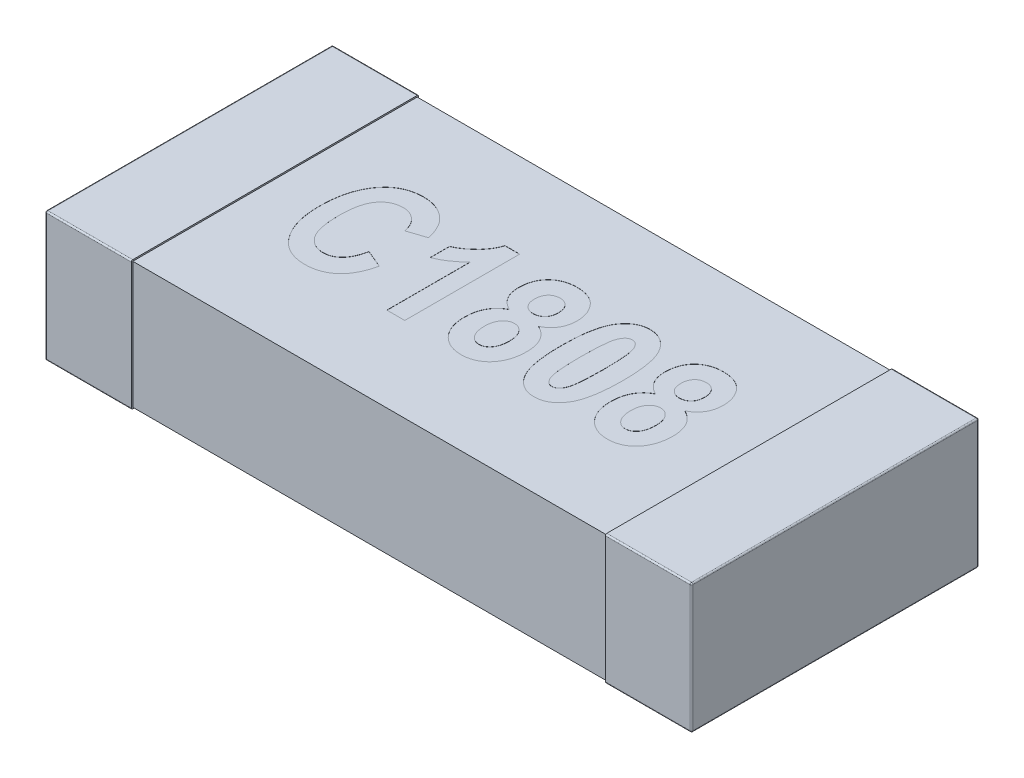
from build123d import *

# Parameters (mm, degrees)
SKETCH1_W            = 0.6
SKETCH1_H            = 2
THICKNESS_DEPTH      = 0.9
FILLET1_R            = 0.01
SKETCH2_W            = 1.98
SKETCH2_H            = 0.88
BOSS_EXTRUDE2_DEPTH  = 1.65
FILLET1_OF_MIRROR3_R = 0.01
CUT_EXTRUDE1_DEPTH   = 0.001


with BuildPart() as part:
    # Sketch1 → THICKNESS (new body)
    with BuildSketch(Plane(origin=(0, 0, 0), x_dir=(1, 0, 0), z_dir=(0, 1, 0))):
        with Locations((-1.95, 0)):
            Rectangle(SKETCH1_W, SKETCH1_H)
    thickness = extrude(amount=THICKNESS_DEPTH)

    # Fillet1
    fillet1_edges = [part.edges().sort_by_distance(p)[0] for p in [
        (-1.95, 0.9, -1),
        (-2.25, 0.9, 0),
        (-1.95, 0, -1),
        (-1.95, 0, 1),
        (-2.25, 0, 0),
        (-1.95, 0.9, 1),
        (-2.25, 0.45, -1),
        (-2.25, 0.45, 1),
    ]]
    fillet(fillet1_edges, radius=FILLET1_R)

    # Sketch2 → Boss-Extrude2 (add)
    with BuildSketch(Plane(origin=(0, 0, 0), x_dir=(0, 0, -1), z_dir=(1, 0, 0))):
        with Locations((0, 0.45)):
            Rectangle(SKETCH2_W, SKETCH2_H)
    boss_extrude2 = extrude(amount=-BOSS_EXTRUDE2_DEPTH)

    # Mirror3: THICKNESS, Boss-Extrude2 across plane
    add(thickness.mirror(Plane(origin=(0, 0, 0), x_dir=(0, 0, 1), z_dir=(1, 0, 0))))
    add(boss_extrude2.mirror(Plane(origin=(0, 0, 0), x_dir=(0, 0, 1), z_dir=(1, 0, 0))))

    # Fillet1 of Mirror3
    fillet1_of_mirror3_edges = [part.edges().sort_by_distance(p)[0] for p in [
        (1.95, 0.9, -1),
        (2.25, 0.9, 0),
        (1.95, 0, -1),
        (1.95, 0, 1),
        (2.25, 0, 0),
        (1.95, 0.9, 1),
        (2.25, 0.45, -1),
        (2.25, 0.45, 1),
    ]]
    fillet(fillet1_of_mirror3_edges, radius=FILLET1_OF_MIRROR3_R)

    # Sketch3 → Cut-Extrude1 (cut)
    with BuildSketch(Plane(origin=(0, 0.89, 0), x_dir=(1, 0, 0), z_dir=(0, 1, 0))):
        with BuildLine():
            Line((-0.886688312, -0.109090909), (-0.762012987, -0.161038961))
            add(Edge.make_bspline(
                [(-0.762012987, -0.161038961), (-0.764587888, -0.171519071), (-0.76960521, -0.191940082), (-0.779097291, -0.221127447), (-0.789542242, -0.248208875), (-0.801491852, -0.273032784), (-0.814536431, -0.29581696), (-0.829026304, -0.3163372), (-0.844688859, -0.334698569), (-0.861613178, -0.350858163), (-0.879771815, -0.364762202), (-0.898654923, -0.377152112), (-0.918750118, -0.3873092), (-0.939776014, -0.395885297), (-0.961897913, -0.402260201), (-0.984947737, -0.407057579), (-1.009024422, -0.409802863), (-1.025426179, -0.410191828), (-1.033766234, -0.41038961)],
                knots=[0, 0, 0, 0, 3.2366e-05, 6.3066e-05, 9.2006e-05, 0.00011938, 0.000145637, 0.000170679, 0.000194626, 0.000217936, 0.000240731, 0.000263155, 0.000285589, 0.000308168, 0.000331181, 0.00035455, 0.000378734, 0.000403753, 0.000403753, 0.000403753, 0.000403753], degree=3))
            add(Edge.make_bspline(
                [(-1.033766234, -0.41038961), (-1.044230463, -0.410154349), (-1.064729641, -0.409693477), (-1.094641881, -0.404734609), (-1.123105955, -0.397200474), (-1.150070553, -0.386381408), (-1.17556765, -0.372552339), (-1.199327892, -0.355423005), (-1.221905703, -0.335631103), (-1.235033145, -0.320199252), (-1.241720779, -0.312337662)],
                knots=[0, 0, 0, 0, 3.1365e-05, 6.1444e-05, 9.0703e-05, 0.000119552, 0.000148392, 0.000177492, 0.000207272, 0.000238198, 0.000238198, 0.000238198, 0.000238198], degree=3))
            add(Edge.make_bspline(
                [(-1.241720779, -0.312337662), (-1.249071833, -0.302631543), (-1.263881209, -0.283077668), (-1.282473559, -0.250833362), (-1.298286709, -0.216192275), (-1.311228993, -0.179123009), (-1.321316821, -0.139584496), (-1.328369523, -0.097557885), (-1.332604885, -0.053063505), (-1.333158439, -0.022574403), (-1.333441558, -0.006980519)],
                knots=[0, 0, 0, 0, 3.6498e-05, 7.3529e-05, 0.000111376, 0.000150601, 0.000191156, 0.000233644, 0.000278324, 0.0003251, 0.0003251, 0.0003251, 0.0003251], degree=3))
            add(Edge.make_bspline(
                [(-1.333441558, -0.006980519), (-1.333182908, 0.009481029), (-1.332679101, 0.041545363), (-1.328143083, 0.088227985), (-1.321228117, 0.132238588), (-1.31091819, 0.17341359), (-1.298002736, 0.211989422), (-1.282045729, 0.24772553), (-1.263518042, 0.280995659), (-1.248401568, 0.300865703), (-1.240909091, 0.310714286)],
                knots=[0, 0, 0, 0, 4.9372e-05, 9.6169e-05, 0.000140578, 0.000182904, 0.000223357, 0.000262454, 0.000300188, 0.000337271, 0.000337271, 0.000337271, 0.000337271], degree=3))
            add(Edge.make_bspline(
                [(-1.240909091, 0.310714286), (-1.234106292, 0.318675312), (-1.220699433, 0.334364788), (-1.197783924, 0.354681556), (-1.173165471, 0.371951533), (-1.146852985, 0.386091256), (-1.118728726, 0.397088672), (-1.08893034, 0.40484862), (-1.057338522, 0.4094273), (-1.035729472, 0.410063938), (-1.024675325, 0.41038961)],
                knots=[0, 0, 0, 0, 3.1385e-05, 6.1853e-05, 9.1577e-05, 0.000121428, 0.000151242, 0.000181955, 0.000213614, 0.000246771, 0.000246771, 0.000246771, 0.000246771], degree=3))
            add(Edge.make_bspline(
                [(-1.024675325, 0.41038961), (-1.015628999, 0.410173075), (-0.997848872, 0.409747484), (-0.971777538, 0.406345119), (-0.946938184, 0.400362535), (-0.923088339, 0.392515252), (-0.900437251, 0.382015668), (-0.878919422, 0.369275036), (-0.858450234, 0.354335243), (-0.846043536, 0.342720947), (-0.839772727, 0.336850649)],
                knots=[0, 0, 0, 0, 2.7134e-05, 5.3331e-05, 7.8689e-05, 0.000103689, 0.000128531, 0.000153422, 0.000178617, 0.000204367, 0.000204367, 0.000204367, 0.000204367], degree=3))
            add(Edge.make_bspline(
                [(-0.839772727, 0.336850649), (-0.835412695, 0.332326305), (-0.826528176, 0.323106963), (-0.81456515, 0.307577558), (-0.803489465, 0.290474927), (-0.793499694, 0.271726086), (-0.784212521, 0.251514282), (-0.775767536, 0.229735912), (-0.768338302, 0.20634143), (-0.764153998, 0.190118882), (-0.762012987, 0.181818182)],
                knots=[0, 0, 0, 0, 1.8838e-05, 3.8387e-05, 5.8695e-05, 7.9904e-05, 0.000102059, 0.000125392, 0.000149933, 0.000175647, 0.000175647, 0.000175647, 0.000175647], degree=3))
            Line((-0.762012987, 0.181818182), (-0.886688312, 0.14025974))
            add(Edge.make_bspline(
                [(-0.886688312, 0.14025974), (-0.887859879, 0.145580721), (-0.890139554, 0.155934467), (-0.894716563, 0.170876331), (-0.900288888, 0.184754353), (-0.90635165, 0.197901695), (-0.913652225, 0.20986361), (-0.921288857, 0.221211647), (-0.930243522, 0.231265568), (-0.939703879, 0.240553667), (-0.950003619, 0.248580124), (-0.960546329, 0.255838802), (-0.971646328, 0.26187386), (-0.983257314, 0.266727565), (-0.995241765, 0.270655679), (-1.007688983, 0.273418025), (-1.020570484, 0.275090808), (-1.029323898, 0.275245944), (-1.033766234, 0.275324675)],
                knots=[0, 0, 0, 0, 1.6341e-05, 3.1798e-05, 4.681e-05, 6.1188e-05, 7.5164e-05, 8.8809e-05, 0.000102156, 0.000115474, 0.000128531, 0.000141273, 0.00015384, 0.000166353, 0.000178982, 0.000191624, 0.000204551, 0.000217872, 0.000217872, 0.000217872, 0.000217872], degree=3))
            add(Edge.make_bspline(
                [(-1.033766234, 0.275324675), (-1.040053241, 0.275138273), (-1.052426715, 0.274771413), (-1.07055492, 0.271852603), (-1.087706664, 0.266690043), (-1.104140173, 0.259912618), (-1.119579304, 0.25088307), (-1.134195929, 0.239948161), (-1.147597023, 0.226777428), (-1.160440558, 0.211962615), (-1.172078974, 0.194797792), (-1.181960783, 0.174959821), (-1.190111483, 0.152519523), (-1.197132349, 0.127637839), (-1.202385248, 0.100151294), (-1.206030598, 0.070102452), (-1.208305708, 0.037534889), (-1.208609195, 0.014938972), (-1.208766234, 0.003246753)],
                knots=[0, 0, 0, 0, 1.8856e-05, 3.7111e-05, 5.4884e-05, 7.2491e-05, 9.0312e-05, 0.000108396, 0.00012711, 0.000146567, 0.000167144, 0.000189141, 0.000212873, 0.000238673, 0.000266626, 0.000296728, 0.000329437, 0.000364512, 0.000364512, 0.000364512, 0.000364512], degree=3))
            add(Edge.make_bspline(
                [(-1.208766234, 0.003246753), (-1.208588788, -0.008876697), (-1.208247081, -0.032222791), (-1.206255203, -0.065942376), (-1.202469117, -0.096922951), (-1.197622639, -0.125286334), (-1.190990688, -0.150866739), (-1.182888479, -0.173679833), (-1.173556023, -0.193948332), (-1.162423404, -0.21140631), (-1.150088241, -0.226477742), (-1.136973708, -0.239563029), (-1.122826613, -0.250493966), (-1.108025428, -0.259757872), (-1.0921638, -0.266777814), (-1.075429381, -0.271554026), (-1.057921414, -0.2748575), (-1.04590329, -0.275166865), (-1.039772727, -0.275324675)],
                knots=[0, 0, 0, 0, 3.6373e-05, 7.0043e-05, 0.000101273, 0.000129965, 0.000156307, 0.00018044, 0.000202516, 0.000223097, 0.000242366, 0.000260848, 0.000278545, 0.000295891, 0.000313116, 0.000330376, 0.000348017, 0.000366387, 0.000366387, 0.000366387, 0.000366387], degree=3))
            add(Edge.make_bspline(
                [(-1.039772727, -0.275324675), (-1.035276477, -0.275185424), (-1.026357177, -0.274909188), (-1.013232349, -0.273150197), (-1.00056711, -0.270005154), (-0.988359752, -0.265641764), (-0.976662302, -0.259884829), (-0.965354745, -0.253064532), (-0.954665507, -0.244866461), (-0.944317228, -0.235557954), (-0.934556934, -0.224851527), (-0.925636771, -0.21254215), (-0.917348931, -0.198849825), (-0.909743519, -0.183689634), (-0.902772029, -0.167159014), (-0.896625224, -0.149131112), (-0.891062936, -0.129695933), (-0.888174607, -0.116091544), (-0.886688312, -0.109090909)],
                knots=[0, 0, 0, 0, 1.349e-05, 2.676e-05, 3.9635e-05, 5.2575e-05, 6.5571e-05, 7.8684e-05, 9.2126e-05, 0.000105918, 0.000120398, 0.000135496, 0.000151449, 0.000168365, 0.000186335, 0.000205227, 0.000225475, 0.000246939, 0.000246939, 0.000246939, 0.000246939], degree=3))
        make_face()
        with BuildLine():
            Line((-0.346428571, -0.4), (-0.471103896, -0.4))
            Line((-0.471103896, -0.4), (-0.471103896, 0.181818182))
            add(Edge.make_bspline(
                [(-0.471103896, 0.181818182), (-0.477150623, 0.175473091), (-0.489142698, 0.162889291), (-0.508221205, 0.145321837), (-0.527959547, 0.129125556), (-0.548487968, 0.11422702), (-0.569571575, 0.100484821), (-0.591477089, 0.088080675), (-0.614018763, 0.076988684), (-0.629559083, 0.070686815), (-0.637337662, 0.067532468)],
                knots=[0, 0, 0, 0, 2.6289e-05, 5.2138e-05, 7.7746e-05, 0.000102846, 0.000128196, 0.000153205, 0.000178325, 0.0002035, 0.0002035, 0.0002035, 0.0002035], degree=3))
            Line((-0.637337662, 0.067532468), (-0.637337662, 0.202597403))
            add(Edge.make_bspline(
                [(-0.637337662, 0.202597403), (-0.628371684, 0.206582281), (-0.609705024, 0.214878574), (-0.582396668, 0.231535803), (-0.55481633, 0.252395472), (-0.531931447, 0.272419113), (-0.51408208, 0.29023418), (-0.501363771, 0.304265743), (-0.489977606, 0.319086366), (-0.479425534, 0.334167018), (-0.470108745, 0.349938964), (-0.461883323, 0.366099424), (-0.454584525, 0.382753814), (-0.45077734, 0.39423095), (-0.448863636, 0.4)],
                knots=[0, 0, 0, 0, 2.9412e-05, 6.1234e-05, 9.5682e-05, 0.000133066, 0.000152351, 0.00017132, 0.000189829, 0.000208382, 0.000226506, 0.000244729, 0.000262763, 0.000280989, 0.000280989, 0.000280989, 0.000280989], degree=3))
            Line((-0.448863636, 0.4), (-0.346428571, 0.4))
            Line((-0.346428571, 0.4), (-0.346428571, -0.4))
        make_face()
        with BuildLine():
            add(Edge.make_bspline(
                [(-0.049025974, 0.030194805), (-0.056961649, 0.034289498), (-0.072393267, 0.042251989), (-0.092687833, 0.057866208), (-0.11014289, 0.075289566), (-0.124466535, 0.095053818), (-0.135608703, 0.117017351), (-0.143309459, 0.141142576), (-0.148157107, 0.167285213), (-0.148729703, 0.185421294), (-0.149025974, 0.194805195)],
                knots=[0, 0, 0, 0, 2.6742e-05, 5.2002e-05, 7.6453e-05, 0.000100514, 0.000124908, 0.000150012, 0.000176249, 0.00020438, 0.00020438, 0.00020438, 0.00020438], degree=3))
            add(Edge.make_bspline(
                [(-0.149025974, 0.194805195), (-0.148890837, 0.202442803), (-0.148627391, 0.217332067), (-0.145973124, 0.23906742), (-0.141595765, 0.259598346), (-0.135561916, 0.278993004), (-0.128033077, 0.297339929), (-0.118285355, 0.314262032), (-0.107103341, 0.330091797), (-0.094237659, 0.34455496), (-0.079933155, 0.357571406), (-0.06431889, 0.36895612), (-0.047466537, 0.378651123), (-0.029374701, 0.386338249), (-0.01023269, 0.392637494), (0.010124495, 0.396930514), (0.031692052, 0.399606254), (0.046474437, 0.399866489), (0.054058442, 0.4)],
                knots=[0, 0, 0, 0, 2.2904e-05, 4.4651e-05, 6.5569e-05, 8.58e-05, 0.000105518, 0.000124928, 0.000144253, 0.000163572, 0.000182878, 0.000202166, 0.000221435, 0.000241068, 0.000261038, 0.000281798, 0.000303383, 0.000326125, 0.000326125, 0.000326125, 0.000326125], degree=3))
            add(Edge.make_bspline(
                [(0.054058442, 0.4), (0.062075248, 0.399811515), (0.077617509, 0.399446096), (0.100234222, 0.396663258), (0.12133993, 0.392011797), (0.141017812, 0.385444947), (0.159305494, 0.37725539), (0.176027567, 0.366900237), (0.191211201, 0.354650482), (0.204773826, 0.340619318), (0.216923284, 0.32546527), (0.22732873, 0.309231757), (0.23631639, 0.29232579), (0.243699728, 0.27457668), (0.249111212, 0.255974301), (0.253255476, 0.236675322), (0.255715244, 0.216513875), (0.256015981, 0.202766417), (0.256168831, 0.195779221)],
                knots=[0, 0, 0, 0, 2.4046e-05, 4.6618e-05, 6.824e-05, 8.8775e-05, 0.000108753, 0.000128215, 0.00014761, 0.000167126, 0.000186647, 0.000205785, 0.000224883, 0.000244027, 0.000263339, 0.00028292, 0.000303196, 0.000324154, 0.000324154, 0.000324154, 0.000324154], degree=3))
            add(Edge.make_bspline(
                [(0.256168831, 0.195779221), (0.255911571, 0.186388447), (0.25541062, 0.168102179), (0.249925656, 0.141702748), (0.241678815, 0.117056292), (0.229441072, 0.094783383), (0.214620369, 0.074698068), (0.197260686, 0.056968797), (0.177307562, 0.041799861), (0.162411335, 0.034095256), (0.15487013, 0.030194805)],
                knots=[0, 0, 0, 0, 2.8131e-05, 5.4779e-05, 8.0551e-05, 0.000105829, 0.000130667, 0.000155233, 0.000180038, 0.000205471, 0.000205471, 0.000205471, 0.000205471], degree=3))
            add(Edge.make_bspline(
                [(0.15487013, 0.030194805), (0.163810512, 0.025549017), (0.181288056, 0.01646697), (0.204124514, -0.001639534), (0.223826449, -0.021981465), (0.239524363, -0.045486042), (0.251840271, -0.071566277), (0.260321322, -0.100487153), (0.265610926, -0.13211172), (0.266234607, -0.154144365), (0.266558442, -0.165584416)],
                knots=[0, 0, 0, 0, 3.0164e-05, 5.8967e-05, 8.6984e-05, 0.00011481, 0.000143349, 0.000173188, 0.000204947, 0.000239247, 0.000239247, 0.000239247, 0.000239247], degree=3))
            add(Edge.make_bspline(
                [(0.266558442, -0.165584416), (0.266296793, -0.177457267), (0.265786334, -0.200620367), (0.260354769, -0.234236613), (0.25207578, -0.265862021), (0.240059298, -0.295010947), (0.225119754, -0.321374505), (0.207674505, -0.344804252), (0.187328186, -0.364794847), (0.164542718, -0.381357287), (0.139802517, -0.394493006), (0.113249589, -0.403495834), (0.085387858, -0.409501431), (0.066211524, -0.410090889), (0.056493506, -0.41038961)],
                knots=[0, 0, 0, 0, 3.5589e-05, 6.9432e-05, 0.00010188, 0.000133474, 0.000163717, 0.000192581, 0.00022082, 0.00024894, 0.000276824, 0.000304497, 0.000332832, 0.000361945, 0.000361945, 0.000361945, 0.000361945], degree=3))
            add(Edge.make_bspline(
                [(0.056493506, -0.41038961), (0.048851687, -0.410226311), (0.033827804, -0.409905264), (0.011824743, -0.406664674), (-0.009219653, -0.40175674), (-0.029145663, -0.394484672), (-0.04813916, -0.385400342), (-0.066027343, -0.374076348), (-0.083031047, -0.36090887), (-0.09871715, -0.345627403), (-0.112954758, -0.328685067), (-0.125380338, -0.310162735), (-0.135954767, -0.290319595), (-0.144603386, -0.269052508), (-0.15126761, -0.246369539), (-0.155853622, -0.222277793), (-0.158908476, -0.196831112), (-0.159243747, -0.179392425), (-0.159415584, -0.170454545)],
                knots=[0, 0, 0, 0, 2.291e-05, 4.5042e-05, 6.658e-05, 8.7634e-05, 0.000108544, 0.000129624, 0.000151023, 0.000172951, 0.000195191, 0.000217298, 0.000239739, 0.00026253, 0.000286056, 0.000310539, 0.000336031, 0.000362835, 0.000362835, 0.000362835, 0.000362835], degree=3))
            add(Edge.make_bspline(
                [(-0.159415584, -0.170454545), (-0.159099384, -0.158959762), (-0.158487131, -0.136702627), (-0.153010205, -0.104578718), (-0.144170569, -0.074939722), (-0.131562525, -0.04788236), (-0.115620965, -0.02361732), (-0.096576145, -0.002182855), (-0.074324273, 0.016102866), (-0.057519346, 0.025463733), (-0.049025974, 0.030194805)],
                knots=[0, 0, 0, 0, 3.4462e-05, 6.6728e-05, 9.7438e-05, 0.000126996, 0.000155948, 0.000184232, 0.00021273, 0.000241851, 0.000241851, 0.000241851, 0.000241851], degree=3))
        make_face()
        with BuildLine():
            add(Edge.make_bspline(
                [(-0.024350649, 0.18262987), (-0.024105146, 0.1754607), (-0.023638642, 0.161837922), (-0.019211523, 0.14268253), (-0.011964929, 0.126030508), (-0.001487444, 0.11238673), (0.011002662, 0.101542326), (0.025433726, 0.093990918), (0.041230066, 0.088988052), (0.052395645, 0.08854084), (0.058116883, 0.088311688)],
                knots=[0, 0, 0, 0, 2.1478e-05, 4.0813e-05, 5.8615e-05, 7.553e-05, 9.1994e-05, 0.000107827, 0.000124107, 0.000141215, 0.000141215, 0.000141215, 0.000141215], degree=3))
            add(Edge.make_bspline(
                [(0.058116883, 0.088311688), (0.063944725, 0.088542885), (0.075319427, 0.088994131), (0.091400564, 0.093953679), (0.106033842, 0.101538569), (0.118690332, 0.112375238), (0.129319437, 0.126017694), (0.136781826, 0.142643257), (0.141158592, 0.161842969), (0.141633297, 0.17546244), (0.141883117, 0.18262987)],
                knots=[0, 0, 0, 0, 1.7431e-05, 3.4023e-05, 4.9999e-05, 6.6586e-05, 8.36e-05, 0.000101469, 0.000120804, 0.000142282, 0.000142282, 0.000142282, 0.000142282], degree=3))
            add(Edge.make_bspline(
                [(0.141883117, 0.18262987), (0.141632254, 0.189581166), (0.141154253, 0.202826359), (0.136770143, 0.22147464), (0.1293554, 0.237694757), (0.119044228, 0.251278908), (0.10650062, 0.261994784), (0.092352475, 0.269895866), (0.07659071, 0.274582722), (0.065561953, 0.275073061), (0.059902597, 0.275324675)],
                knots=[0, 0, 0, 0, 2.0831e-05, 3.9691e-05, 5.705e-05, 7.3966e-05, 9.0429e-05, 0.000106197, 0.000122275, 0.000139221, 0.000139221, 0.000139221, 0.000139221], degree=3))
            add(Edge.make_bspline(
                [(0.059902597, 0.275324675), (0.054022043, 0.275090615), (0.04254387, 0.274633756), (0.026264532, 0.269706753), (0.011509796, 0.261969013), (-0.001100132, 0.250932833), (-0.01175278, 0.237409212), (-0.018947505, 0.221034499), (-0.023683941, 0.202592525), (-0.024121848, 0.189480667), (-0.024350649, 0.18262987)],
                knots=[0, 0, 0, 0, 1.7593e-05, 3.434e-05, 5.0536e-05, 6.7228e-05, 8.4242e-05, 0.000101749, 0.00012049, 0.000140997, 0.000140997, 0.000140997, 0.000140997], degree=3))
        make_face(mode=Mode.SUBTRACT)
        with BuildLine():
            add(Edge.make_bspline(
                [(-0.03474026, -0.155519481), (-0.034484294, -0.165340079), (-0.033998203, -0.183989845), (-0.028914, -0.210136463), (-0.02092847, -0.232967466), (-0.00939009, -0.251943003), (0.00463015, -0.26677315), (0.020030019, -0.277803168), (0.03703609, -0.284516879), (0.048915127, -0.285314457), (0.05487013, -0.285714286)],
                knots=[0, 0, 0, 0, 2.9428e-05, 5.5885e-05, 7.956e-05, 0.000101639, 0.000121965, 0.000140384, 0.000158112, 0.000175932, 0.000175932, 0.000175932, 0.000175932], degree=3))
            add(Edge.make_bspline(
                [(0.05487013, -0.285714286), (0.060827435, -0.28538414), (0.072596347, -0.284731924), (0.089262537, -0.278127894), (0.104241375, -0.267659471), (0.115205054, -0.256020051), (0.122783177, -0.244747692), (0.128053117, -0.235191103), (0.132209049, -0.224448759), (0.135762333, -0.212844429), (0.138551216, -0.200197614), (0.140389148, -0.186512503), (0.141800609, -0.171836295), (0.141855161, -0.161692044), (0.141883117, -0.156493506)],
                knots=[0, 0, 0, 0, 1.7802e-05, 3.5168e-05, 5.291e-05, 7.2318e-05, 8.2719e-05, 9.3615e-05, 0.00010498, 0.000117201, 0.000130002, 0.000143777, 0.000158607, 0.000174195, 0.000174195, 0.000174195, 0.000174195], degree=3))
            add(Edge.make_bspline(
                [(0.141883117, -0.156493506), (0.14158772, -0.14770534), (0.141024986, -0.130963771), (0.136357599, -0.107176263), (0.128282188, -0.086276945), (0.116991313, -0.068629851), (0.103595394, -0.054338986), (0.08826087, -0.043949656), (0.071290895, -0.037343386), (0.05931214, -0.036692971), (0.053246753, -0.036363636)],
                knots=[0, 0, 0, 0, 2.6349e-05, 5.0195e-05, 7.2352e-05, 9.3157e-05, 0.000112677, 0.000130687, 0.000148357, 0.000166481, 0.000166481, 0.000166481, 0.000166481], degree=3))
            add(Edge.make_bspline(
                [(0.053246753, -0.036363636), (0.047297946, -0.036783445), (0.035520018, -0.037614615), (0.018598725, -0.043919308), (0.003383141, -0.054538111), (-0.009961313, -0.068937057), (-0.021263519, -0.086487716), (-0.029177717, -0.107202042), (-0.033874127, -0.130525407), (-0.034443176, -0.146946517), (-0.03474026, -0.155519481)],
                knots=[0, 0, 0, 0, 1.782e-05, 3.5282e-05, 5.3383e-05, 7.3021e-05, 9.3826e-05, 0.000115621, 0.000139149, 0.00016485, 0.00016485, 0.00016485, 0.00016485], degree=3))
        make_face(mode=Mode.SUBTRACT)
        with BuildLine():
            add(Edge.make_bspline(
                [(0.562337662, 0.4), (0.570095156, 0.399714867), (0.58540237, 0.399152239), (0.607736018, 0.394826767), (0.628997578, 0.387799444), (0.649040155, 0.377830345), (0.667875993, 0.364990268), (0.685552417, 0.349357532), (0.702083278, 0.330938836), (0.71757489, 0.309568872), (0.731496165, 0.284575627), (0.743385873, 0.255509326), (0.753371267, 0.222269614), (0.761507913, 0.184860519), (0.767962469, 0.143228892), (0.772333577, 0.097370919), (0.775116544, 0.04732879), (0.775467095, 0.012558129), (0.775649351, -0.005519481)],
                knots=[0, 0, 0, 0, 2.326e-05, 4.5897e-05, 6.7972e-05, 9.026e-05, 0.000112818, 0.000136168, 0.00016088, 0.000186923, 0.000215195, 0.000246488, 0.000280946, 0.00031919, 0.000361253, 0.000407257, 0.000457333, 0.000511563, 0.000511563, 0.000511563, 0.000511563], degree=3))
            add(Edge.make_bspline(
                [(0.775649351, -0.005519481), (0.775466696, -0.023542903), (0.775115418, -0.058205268), (0.772338662, -0.108086407), (0.767943005, -0.153831748), (0.761540884, -0.195366663), (0.753306584, -0.23274867), (0.743461961, -0.265981314), (0.731447896, -0.294998057), (0.717589901, -0.319969414), (0.702069547, -0.341268545), (0.68571869, -0.359797909), (0.668033394, -0.375379213), (0.649233532, -0.388171044), (0.629288946, -0.398233668), (0.608155652, -0.405159659), (0.585950873, -0.409573449), (0.570746367, -0.410113834), (0.562987013, -0.41038961)],
                knots=[0, 0, 0, 0, 5.4067e-05, 0.000103981, 0.000149824, 0.000191887, 0.000229973, 0.000264585, 0.000295729, 0.000324001, 0.000350044, 0.000374647, 0.000397997, 0.000420555, 0.000442698, 0.000464773, 0.000487091, 0.000510351, 0.000510351, 0.000510351, 0.000510351], degree=3))
            add(Edge.make_bspline(
                [(0.562987013, -0.41038961), (0.555232824, -0.410086264), (0.539942034, -0.409488082), (0.517570478, -0.405428294), (0.496324314, -0.398345223), (0.476331916, -0.388367291), (0.457447346, -0.375721428), (0.439779952, -0.360236026), (0.423226785, -0.341995002), (0.410642435, -0.324635369), (0.401179879, -0.309287885), (0.394578839, -0.29645088), (0.388426394, -0.282547938), (0.382504387, -0.267657611), (0.377429871, -0.251488583), (0.372534472, -0.234347489), (0.368139968, -0.216096841), (0.364348147, -0.196793199), (0.360640211, -0.176477297), (0.35788405, -0.155000333), (0.355156885, -0.132509002), (0.353347254, -0.108832198), (0.351652944, -0.084161276), (0.350609142, -0.058339009), (0.349671801, -0.031500194), (0.349674137, -0.013204396), (0.349675325, -0.003896104)],
                knots=[0, 0, 0, 0, 2.326e-05, 4.5868e-05, 6.7942e-05, 9.023e-05, 0.000112697, 0.000135941, 0.000160533, 0.000186444, 0.000200142, 0.000214591, 0.000229706, 0.000245744, 0.000262634, 0.000280518, 0.00029922, 0.000318927, 0.000339532, 0.000361158, 0.000383872, 0.000407492, 0.000432382, 0.000458057, 0.000485017, 0.00051294, 0.00051294, 0.00051294, 0.00051294], degree=3))
            add(Edge.make_bspline(
                [(0.349675325, -0.003896104), (0.34985745, 0.014073306), (0.350207668, 0.048627715), (0.352990478, 0.098345544), (0.357359414, 0.143879551), (0.363826343, 0.185239897), (0.371983926, 0.222477336), (0.381896504, 0.255635519), (0.39387356, 0.284609395), (0.407735531, 0.309579581), (0.423254944, 0.330878989), (0.439606031, 0.349408286), (0.45729127, 0.364989606), (0.476091146, 0.377781433), (0.496035728, 0.387844058), (0.517169024, 0.394770049), (0.539373803, 0.399183839), (0.554578308, 0.399724224), (0.562337662, 0.4)],
                knots=[0, 0, 0, 0, 5.3905e-05, 0.000103657, 0.000149338, 0.00019108, 0.000229166, 0.000263623, 0.000294767, 0.000323039, 0.000349082, 0.000373685, 0.000397035, 0.000419593, 0.000441736, 0.000463811, 0.000486129, 0.000509389, 0.000509389, 0.000509389, 0.000509389], degree=3))
        make_face()
        with BuildLine():
            add(Edge.make_bspline(
                [(0.562662338, 0.275324675), (0.559779187, 0.275158842), (0.554031769, 0.274828261), (0.545673533, 0.272457133), (0.537720505, 0.268684582), (0.530323522, 0.263193657), (0.523533925, 0.256057215), (0.517013984, 0.24759334), (0.511019089, 0.237557449), (0.505262998, 0.225703153), (0.500371551, 0.210817375), (0.496063952, 0.192252803), (0.492675303, 0.169496366), (0.489839832, 0.142572035), (0.487376566, 0.111505632), (0.485884466, 0.076202688), (0.484896623, 0.036748191), (0.484794111, 0.009037528), (0.48474026, -0.005519481)],
                knots=[0, 0, 0, 0, 8.642e-06, 1.7228e-05, 2.5868e-05, 3.4927e-05, 4.4685e-05, 5.5335e-05, 6.6917e-05, 7.9696e-05, 9.4789e-05, 0.000113808, 0.000136814, 0.000163759, 0.000195022, 0.000230287, 0.000269747, 0.000313417, 0.000313417, 0.000313417, 0.000313417], degree=3))
            add(Edge.make_bspline(
                [(0.48474026, -0.005519481), (0.48479314, -0.020076532), (0.484893606, -0.047733181), (0.485890814, -0.087133063), (0.487364275, -0.12232924), (0.489864998, -0.153392034), (0.49264557, -0.180268425), (0.496079601, -0.203019887), (0.500380846, -0.221526938), (0.505219029, -0.236384325), (0.511060205, -0.248145159), (0.517019884, -0.258137185), (0.523477257, -0.266611807), (0.530380364, -0.273580871), (0.537714138, -0.279080498), (0.545675185, -0.282845108), (0.554031354, -0.285218283), (0.559779049, -0.28554859), (0.562662338, -0.285714286)],
                knots=[0, 0, 0, 0, 4.367e-05, 8.2968e-05, 0.000118232, 0.000149334, 0.00017644, 0.000199286, 0.000218305, 0.000233398, 0.000246031, 0.000257613, 0.000268263, 0.000277905, 0.000286964, 0.000295605, 0.00030419, 0.000312832, 0.000312832, 0.000312832, 0.000312832], degree=3))
            add(Edge.make_bspline(
                [(0.562662338, -0.285714286), (0.565599644, -0.285552029), (0.571401444, -0.285231538), (0.579819311, -0.282854253), (0.587783712, -0.279025381), (0.595324389, -0.273649698), (0.602045418, -0.266444326), (0.60871455, -0.258182517), (0.614423166, -0.248047152), (0.620233361, -0.236265387), (0.625156235, -0.221387851), (0.629151717, -0.202762117), (0.632894283, -0.180072428), (0.635656547, -0.153179805), (0.637898191, -0.122158938), (0.639453546, -0.086971947), (0.64042392, -0.047624583), (0.640529134, -0.020022291), (0.640584416, -0.005519481)],
                knots=[0, 0, 0, 0, 8.804e-06, 1.7389e-05, 2.603e-05, 3.522e-05, 4.4978e-05, 5.55e-05, 6.6998e-05, 7.9778e-05, 9.4871e-05, 0.000113853, 0.000136885, 0.000163829, 0.000194919, 0.000230183, 0.000269481, 0.000312989, 0.000312989, 0.000312989, 0.000312989], degree=3))
            add(Edge.make_bspline(
                [(0.640584416, -0.005519481), (0.640528698, 0.009037419), (0.640422633, 0.036747876), (0.639458626, 0.076203757), (0.637890075, 0.111498182), (0.635665244, 0.142574341), (0.632893754, 0.169520551), (0.629151399, 0.192209825), (0.625157475, 0.21083688), (0.620229916, 0.225710773), (0.614433494, 0.237503186), (0.608660111, 0.247642092), (0.602099849, 0.25604293), (0.595318298, 0.263255358), (0.587785197, 0.268636923), (0.579818929, 0.272464346), (0.571401543, 0.274842004), (0.565599677, 0.275162444), (0.562662338, 0.275324675)],
                knots=[0, 0, 0, 0, 4.367e-05, 8.313e-05, 0.000118395, 0.000149646, 0.000176591, 0.000199623, 0.000218605, 0.000233698, 0.000246477, 0.000257976, 0.000268626, 0.000278384, 0.000287574, 0.000296214, 0.0003048, 0.000313604, 0.000313604, 0.000313604, 0.000313604], degree=3))
        make_face(mode=Mode.SUBTRACT)
        with BuildLine():
            add(Edge.make_bspline(
                [(0.969155844, 0.030194805), (0.961220169, 0.034289498), (0.945788551, 0.042251989), (0.925493985, 0.057866208), (0.908038928, 0.075289566), (0.893715283, 0.095053818), (0.882573115, 0.117017351), (0.87487236, 0.141142576), (0.870024711, 0.167285213), (0.869452115, 0.185421294), (0.869155844, 0.194805195)],
                knots=[0, 0, 0, 0, 2.6742e-05, 5.2002e-05, 7.6453e-05, 0.000100514, 0.000124908, 0.000150012, 0.000176249, 0.00020438, 0.00020438, 0.00020438, 0.00020438], degree=3))
            add(Edge.make_bspline(
                [(0.869155844, 0.194805195), (0.869290982, 0.202442803), (0.869554428, 0.217332067), (0.872208694, 0.23906742), (0.876586053, 0.259598346), (0.882619903, 0.278993004), (0.890148742, 0.297339929), (0.899896463, 0.314262032), (0.911078477, 0.330091797), (0.923944159, 0.34455496), (0.938248663, 0.357571406), (0.953862928, 0.36895612), (0.970715281, 0.378651123), (0.988807117, 0.386338249), (1.007949128, 0.392637494), (1.028306313, 0.396930514), (1.04987387, 0.399606254), (1.064656256, 0.399866489), (1.07224026, 0.4)],
                knots=[0, 0, 0, 0, 2.2904e-05, 4.4651e-05, 6.5569e-05, 8.58e-05, 0.000105518, 0.000124928, 0.000144253, 0.000163572, 0.000182878, 0.000202166, 0.000221435, 0.000241068, 0.000261038, 0.000281798, 0.000303383, 0.000326125, 0.000326125, 0.000326125, 0.000326125], degree=3))
            add(Edge.make_bspline(
                [(1.07224026, 0.4), (1.080257066, 0.399811515), (1.095799327, 0.399446096), (1.118416041, 0.396663258), (1.139521748, 0.392011797), (1.15919963, 0.385444947), (1.177487312, 0.37725539), (1.194209385, 0.366900237), (1.209393019, 0.354650482), (1.222955645, 0.340619318), (1.235105102, 0.32546527), (1.245510548, 0.309231757), (1.254498208, 0.29232579), (1.261881546, 0.27457668), (1.26729303, 0.255974301), (1.271437294, 0.236675322), (1.273897062, 0.216513875), (1.274197799, 0.202766417), (1.274350649, 0.195779221)],
                knots=[0, 0, 0, 0, 2.4046e-05, 4.6618e-05, 6.824e-05, 8.8775e-05, 0.000108753, 0.000128215, 0.00014761, 0.000167126, 0.000186647, 0.000205785, 0.000224883, 0.000244027, 0.000263339, 0.00028292, 0.000303196, 0.000324154, 0.000324154, 0.000324154, 0.000324154], degree=3))
            add(Edge.make_bspline(
                [(1.274350649, 0.195779221), (1.274093389, 0.186388447), (1.273592438, 0.168102179), (1.268107474, 0.141702748), (1.259860633, 0.117056292), (1.24762289, 0.094783383), (1.232802187, 0.074698068), (1.215442505, 0.056968797), (1.195489381, 0.041799861), (1.180593153, 0.034095256), (1.173051948, 0.030194805)],
                knots=[0, 0, 0, 0, 2.8131e-05, 5.4779e-05, 8.0551e-05, 0.000105829, 0.000130667, 0.000155233, 0.000180038, 0.000205471, 0.000205471, 0.000205471, 0.000205471], degree=3))
            add(Edge.make_bspline(
                [(1.173051948, 0.030194805), (1.18199233, 0.025549017), (1.199469874, 0.01646697), (1.222306332, -0.001639534), (1.242008267, -0.021981465), (1.257706181, -0.045486042), (1.270022089, -0.071566277), (1.27850314, -0.100487153), (1.283792744, -0.13211172), (1.284416425, -0.154144365), (1.28474026, -0.165584416)],
                knots=[0, 0, 0, 0, 3.0164e-05, 5.8967e-05, 8.6984e-05, 0.00011481, 0.000143349, 0.000173188, 0.000204947, 0.000239247, 0.000239247, 0.000239247, 0.000239247], degree=3))
            add(Edge.make_bspline(
                [(1.28474026, -0.165584416), (1.284478611, -0.177457267), (1.283968153, -0.200620367), (1.278536587, -0.234236613), (1.270257598, -0.265862021), (1.258241116, -0.295010947), (1.243301573, -0.321374505), (1.225856323, -0.344804252), (1.205510005, -0.364794847), (1.182724536, -0.381357287), (1.157984335, -0.394493006), (1.131431407, -0.403495834), (1.103569676, -0.409501431), (1.084393342, -0.410090889), (1.074675325, -0.41038961)],
                knots=[0, 0, 0, 0, 3.5589e-05, 6.9432e-05, 0.00010188, 0.000133474, 0.000163717, 0.000192581, 0.00022082, 0.00024894, 0.000276824, 0.000304497, 0.000332832, 0.000361945, 0.000361945, 0.000361945, 0.000361945], degree=3))
            add(Edge.make_bspline(
                [(1.074675325, -0.41038961), (1.067033505, -0.410226311), (1.052009622, -0.409905264), (1.030006561, -0.406664674), (1.008962165, -0.40175674), (0.989036155, -0.394484672), (0.970042658, -0.385400342), (0.952154475, -0.374076348), (0.935150771, -0.36090887), (0.919464668, -0.345627403), (0.90522706, -0.328685067), (0.89280148, -0.310162735), (0.882227051, -0.290319595), (0.873578432, -0.269052508), (0.866914209, -0.246369539), (0.862328197, -0.222277793), (0.859273342, -0.196831112), (0.858938071, -0.179392425), (0.858766234, -0.170454545)],
                knots=[0, 0, 0, 0, 2.291e-05, 4.5042e-05, 6.658e-05, 8.7634e-05, 0.000108544, 0.000129624, 0.000151023, 0.000172951, 0.000195191, 0.000217298, 0.000239739, 0.00026253, 0.000286056, 0.000310539, 0.000336031, 0.000362835, 0.000362835, 0.000362835, 0.000362835], degree=3))
            add(Edge.make_bspline(
                [(0.858766234, -0.170454545), (0.859082434, -0.158959762), (0.859694687, -0.136702627), (0.865171613, -0.104578718), (0.874011249, -0.074939722), (0.886619294, -0.04788236), (0.902560853, -0.02361732), (0.921605673, -0.002182855), (0.943857545, 0.016102866), (0.960662472, 0.025463733), (0.969155844, 0.030194805)],
                knots=[0, 0, 0, 0, 3.4462e-05, 6.6728e-05, 9.7438e-05, 0.000126996, 0.000155948, 0.000184232, 0.00021273, 0.000241851, 0.000241851, 0.000241851, 0.000241851], degree=3))
        make_face()
        with BuildLine():
            add(Edge.make_bspline(
                [(0.993831169, 0.18262987), (0.994076673, 0.1754607), (0.994543176, 0.161837922), (0.998970296, 0.14268253), (1.00621689, 0.126030508), (1.016694374, 0.11238673), (1.02918448, 0.101542326), (1.043615544, 0.093990918), (1.059411884, 0.088988052), (1.070577463, 0.08854084), (1.076298701, 0.088311688)],
                knots=[0, 0, 0, 0, 2.1478e-05, 4.0813e-05, 5.8615e-05, 7.553e-05, 9.1994e-05, 0.000107827, 0.000124107, 0.000141215, 0.000141215, 0.000141215, 0.000141215], degree=3))
            add(Edge.make_bspline(
                [(1.076298701, 0.088311688), (1.082126543, 0.088542885), (1.093501245, 0.088994131), (1.109582382, 0.093953679), (1.12421566, 0.101538569), (1.13687215, 0.112375238), (1.147501255, 0.126017694), (1.154963644, 0.142643257), (1.15934041, 0.161842969), (1.159815115, 0.17546244), (1.160064935, 0.18262987)],
                knots=[0, 0, 0, 0, 1.7431e-05, 3.4023e-05, 4.9999e-05, 6.6586e-05, 8.36e-05, 0.000101469, 0.000120804, 0.000142282, 0.000142282, 0.000142282, 0.000142282], degree=3))
            add(Edge.make_bspline(
                [(1.160064935, 0.18262987), (1.159814072, 0.189581166), (1.159336072, 0.202826359), (1.154951961, 0.22147464), (1.147537218, 0.237694757), (1.137226046, 0.251278908), (1.124682438, 0.261994784), (1.110534294, 0.269895866), (1.094772528, 0.274582722), (1.083743771, 0.275073061), (1.078084416, 0.275324675)],
                knots=[0, 0, 0, 0, 2.0831e-05, 3.9691e-05, 5.705e-05, 7.3966e-05, 9.0429e-05, 0.000106197, 0.000122275, 0.000139221, 0.000139221, 0.000139221, 0.000139221], degree=3))
            add(Edge.make_bspline(
                [(1.078084416, 0.275324675), (1.072203862, 0.275090615), (1.060725689, 0.274633756), (1.04444635, 0.269706753), (1.029691614, 0.261969013), (1.017081686, 0.250932833), (1.006429038, 0.237409212), (0.999234313, 0.221034499), (0.994497877, 0.202592525), (0.99405997, 0.189480667), (0.993831169, 0.18262987)],
                knots=[0, 0, 0, 0, 1.7593e-05, 3.434e-05, 5.0536e-05, 6.7228e-05, 8.4242e-05, 0.000101749, 0.00012049, 0.000140997, 0.000140997, 0.000140997, 0.000140997], degree=3))
        make_face(mode=Mode.SUBTRACT)
        with BuildLine():
            add(Edge.make_bspline(
                [(0.983441558, -0.155519481), (0.983697524, -0.165340079), (0.984183615, -0.183989845), (0.989267818, -0.210136463), (0.997253348, -0.232967466), (1.008791728, -0.251943003), (1.022811968, -0.26677315), (1.038211837, -0.277803168), (1.055217908, -0.284516879), (1.067096946, -0.285314457), (1.073051948, -0.285714286)],
                knots=[0, 0, 0, 0, 2.9428e-05, 5.5885e-05, 7.956e-05, 0.000101639, 0.000121965, 0.000140384, 0.000158112, 0.000175932, 0.000175932, 0.000175932, 0.000175932], degree=3))
            add(Edge.make_bspline(
                [(1.073051948, -0.285714286), (1.079009253, -0.28538414), (1.090778165, -0.284731924), (1.107444355, -0.278127894), (1.122423193, -0.267659471), (1.133386872, -0.256020051), (1.140964995, -0.244747692), (1.146234936, -0.235191103), (1.150390867, -0.224448759), (1.153944151, -0.212844429), (1.156733035, -0.200197614), (1.158570966, -0.186512503), (1.159982427, -0.171836295), (1.160036979, -0.161692044), (1.160064935, -0.156493506)],
                knots=[0, 0, 0, 0, 1.7802e-05, 3.5168e-05, 5.291e-05, 7.2318e-05, 8.2719e-05, 9.3615e-05, 0.00010498, 0.000117201, 0.000130002, 0.000143777, 0.000158607, 0.000174195, 0.000174195, 0.000174195, 0.000174195], degree=3))
            add(Edge.make_bspline(
                [(1.160064935, -0.156493506), (1.159769538, -0.14770534), (1.159206804, -0.130963771), (1.154539417, -0.107176263), (1.146464007, -0.086276945), (1.135173131, -0.068629851), (1.121777212, -0.054338986), (1.106442689, -0.043949656), (1.089472713, -0.037343386), (1.077493958, -0.036692971), (1.071428571, -0.036363636)],
                knots=[0, 0, 0, 0, 2.6349e-05, 5.0195e-05, 7.2352e-05, 9.3157e-05, 0.000112677, 0.000130687, 0.000148357, 0.000166481, 0.000166481, 0.000166481, 0.000166481], degree=3))
            add(Edge.make_bspline(
                [(1.071428571, -0.036363636), (1.065479764, -0.036783445), (1.053701836, -0.037614615), (1.036780543, -0.043919308), (1.021564959, -0.054538111), (1.008220506, -0.068937057), (0.996918299, -0.086487716), (0.989004101, -0.107202042), (0.984307691, -0.130525407), (0.983738642, -0.146946517), (0.983441558, -0.155519481)],
                knots=[0, 0, 0, 0, 1.782e-05, 3.5282e-05, 5.3383e-05, 7.3021e-05, 9.3826e-05, 0.000115621, 0.000139149, 0.00016485, 0.00016485, 0.00016485, 0.00016485], degree=3))
        make_face(mode=Mode.SUBTRACT)
    extrude(amount=-CUT_EXTRUDE1_DEPTH, mode=Mode.SUBTRACT)


solid = part.part
